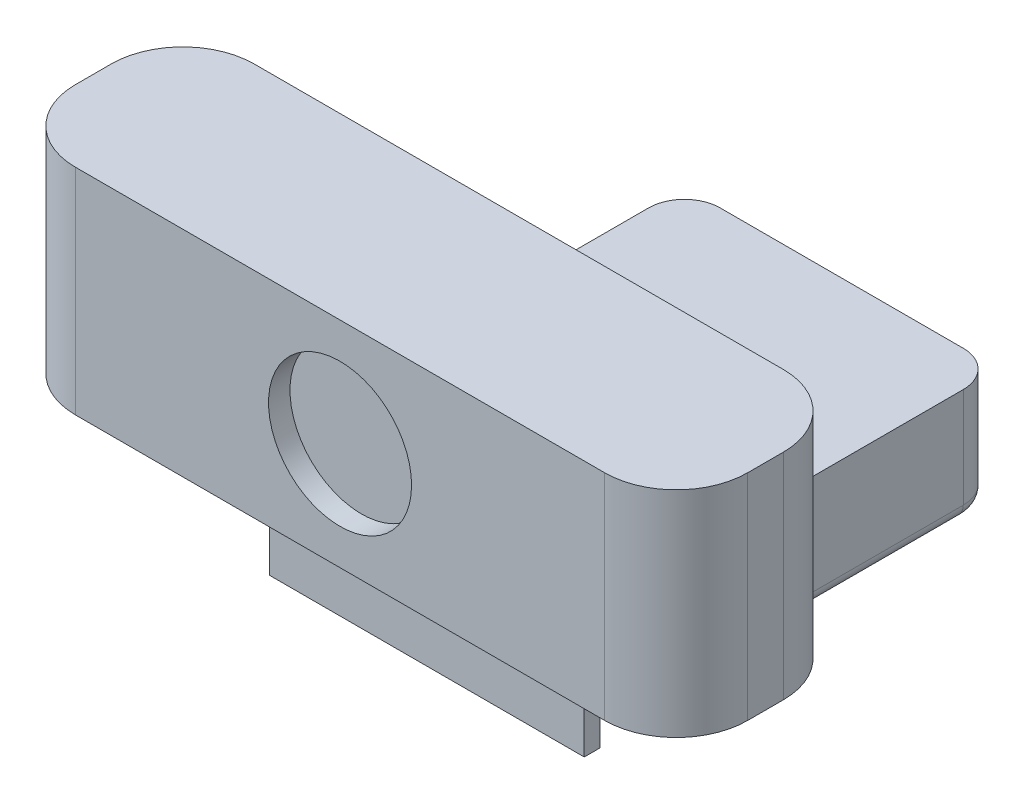
from build123d import *

# Parameters (mm, degrees)
SKETCH1_W           = 44
SKETCH1_H           = 50
BOSS_EXTRUDE1_DEPTH = 10
BOSS_EXTRUDE2_DEPTH = 44
FILLET1_R           = 5
SKETCH3_W           = 94
SKETCH3_H           = 25
BOSS_EXTRUDE3_DEPTH = 30
FILLET2_R           = 10
SKETCH4_R           = 10
CUT_EXTRUDE1_DEPTH  = 3
SKETCH5_R           = 2.5
CUT_EXTRUDE2_DEPTH  = 10
CHAMFER1_SIZE       = 1
FILLET3_R           = 2


with BuildPart() as part:
    # Sketch1 → Boss-Extrude1 (new body)
    with BuildSketch(Plane(origin=(0, 0, 0), x_dir=(1, 0, 0), z_dir=(0, 1, 0))):
        Rectangle(SKETCH1_W, SKETCH1_H)
    extrude(amount=BOSS_EXTRUDE1_DEPTH)

    # Sketch2 → Boss-Extrude2 (add)
    with BuildSketch(Plane(origin=(22, 0, 0), x_dir=(0, 0, -1), z_dir=(1, 0, 0))):
        Polygon((25, 10), (-30.8, 10), (-30.8, -2), (-33, -2), (-33, 10), (-33, 16), (25, 16), align=None)
    extrude(amount=-BOSS_EXTRUDE2_DEPTH)

    # Fillet1
    fillet1_edges = [part.edges().sort_by_distance(p)[0] for p in [
        (22, 5, 25),
        (-22, 5, 25),
        (-22, 8, -25),
        (22, 8, -25),
    ]]
    fillet(fillet1_edges, radius=FILLET1_R)

    # Sketch3 → Boss-Extrude3 (add)
    with BuildSketch(Plane(origin=(0, 16, 0), x_dir=(1, 0, 0), z_dir=(0, 1, 0))):
        with Locations((0, -32.64725537)):
            Rectangle(SKETCH3_W, SKETCH3_H)
    extrude(amount=BOSS_EXTRUDE3_DEPTH)

    # Fillet2
    fillet2_edges = [part.edges().sort_by_distance(p)[0] for p in [
        (47, 31, 45.14725537),
        (47, 31, 20.14725537),
        (-47, 31, 20.14725537),
        (-47, 31, 45.14725537),
    ]]
    fillet(fillet2_edges, radius=FILLET2_R)

    # Sketch4 → Cut-Extrude1 (cut)
    with BuildSketch(Plane.XY.offset(45.14725537)):
        with Locations((0, 31)):
            Circle(SKETCH4_R)
    extrude(amount=-CUT_EXTRUDE1_DEPTH, mode=Mode.SUBTRACT)

    # Sketch5 → Cut-Extrude2 (cut)
    with BuildSketch(Plane.XZ):
        with Locations((0, 5)):
            Circle(SKETCH5_R)
    extrude(amount=-CUT_EXTRUDE2_DEPTH, mode=Mode.SUBTRACT)

    # Chamfer1
    chamfer1_edges = [part.edges().sort_by_distance(p)[0] for p in [
        (-2.5, 0, 5),
    ]]
    chamfer(chamfer1_edges, length=CHAMFER1_SIZE)

    # Fillet3
    fillet3_edges = [part.edges().sort_by_distance(p)[0] for p in [
        (-3.5, 0, 5),
        (0, 0, 25),
        (22, 0, 0),
        (-22, 0, 0),
        (0, 0, -25),
        (20.535533906, 0, 23.535533906),
        (20.535533906, 0, -23.535533906),
        (-20.535533906, 0, -23.535533906),
        (-20.535533906, 0, 23.535533906),
    ]]
    fillet(fillet3_edges, radius=FILLET3_R)


solid = part.part
